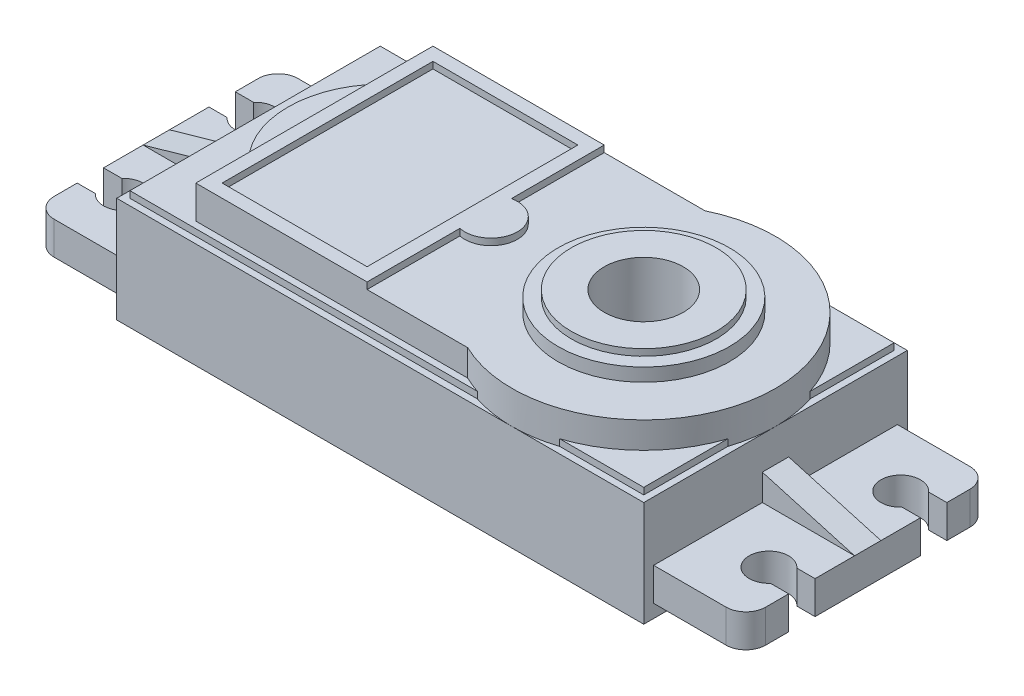
from build123d import *

# Parameters (mm, degrees)
SCHIZZO1_W                   = 40
SCHIZZO1_H                   = 20
ESTRUSIONE_ESTRUSIONE2_DEPTH = 8
TAGLIO_ESTRUSIONE4_DEPTH     = 6
ESTRUSIONE_ESTRUSIONE4_DEPTH = 2.5
SCHIZZO7_W                   = 39
SCHIZZO7_H                   = 19
ESTRUSIONE_ESTRUSIONE3_DEPTH = 0.5
SCHIZZO8_W                   = 11
SCHIZZO8_H                   = 16
ESTRUSIONE_ESTRUSIONE5_DEPTH = 0.5
SCHIZZO9_R                   = 6.5
ESTRUSIONE_ESTRUSIONE6_DEPTH = 1
SCHIZZO10_R                  = 5.5
ESTRUSIONE_ESTRUSIONE7_DEPTH = 0.5
SCHIZZO11_R                  = 3
TAGLIO_ESTRUSIONE5_DEPTH     = 26.377155081
SCHIZZO12_R                  = 1.5
ESTRUSIONE_ESTRUSIONE8_DEPTH = 2.5
TAGLIO_ESTRUSIONE6_DEPTH     = 31.020826105
SPECCHIA4_COPY_1_DEPTH       = 31.020826105
NERVATURA1_REACH             = 33.193
SCHIZZO16_WALL_W             = 71.666005732
SCHIZZO16_WALL_H             = 2


with BuildPart() as part:
    # Schizzo1 → Estrusione-Estrusione2 (new body)
    with BuildSketch(Plane(origin=(0, 0, 0), x_dir=(1, 0, 0), z_dir=(0, 1, 0))):
        Rectangle(SCHIZZO1_W, SCHIZZO1_H)
    extrude(amount=ESTRUSIONE_ESTRUSIONE2_DEPTH)

    # Schizzo2 → Taglio-Estrusione4 (cut)
    with BuildSketch(Plane(origin=(0, 0, 0), x_dir=(1, 0, 0), z_dir=(0, 1, 0))):
        Polygon((16, -8), (-16, -8), (-16, -6), (-18, -6), (-18, 6), (-16, 6), (-16, 8), (16, 8), (16, 6), (18, 6), (18, -6), (16, -6), align=None)
    extrude(amount=TAGLIO_ESTRUSIONE4_DEPTH, mode=Mode.SUBTRACT)

    # Schizzo3 → Foro per Vite M1-1 (revolve, cut)
    with BuildSketch(Plane(origin=(-17.375, 0, 7.375), x_dir=(0, 0, -1), z_dir=(1, 0, 0))):
        Polygon((0, 0), (0, 5.390559402), (0.65, 5), (0.65, 0.025), (0.675, 0), align=None)
    foro_per_vite_m1_1 = revolve(axis=Axis((-17.375, -6.35, 7.375), (0, 1, 0)), mode=Mode.SUBTRACT)

    # Specchia1: Foro per Vite M1-1 across plane
    add(foro_per_vite_m1_1.mirror(Plane(origin=(0, 0, 0), x_dir=(0, 0, 1), z_dir=(1, 0, 0))), mode=Mode.SUBTRACT)

    # Specchia2 copy 1 sketch → Specchia2 copy 1 (revolve, cut)
    with BuildSketch(Plane(origin=(17.375, 0, -7.375), x_dir=(0, 0, 1), z_dir=(-1, 0, 0))):
        Polygon((0, 0), (0, 5.390559402), (0.65, 5), (0.65, 0.025), (0.675, 0), align=None)
    revolve(axis=Axis((17.375, -6.35, -7.375), (0, 1, 0)), mode=Mode.SUBTRACT)

    # Specchia2 copy 2 sketch → Specchia2 copy 2 (revolve, cut)
    with BuildSketch(Plane(origin=(-17.375, 0, -7.375), x_dir=(0, 0, 1), z_dir=(1, 0, 0))):
        Polygon((0, 0), (0, -5.390559402), (0.65, -5), (0.65, -0.025), (0.675, 0), align=None)
    revolve(axis=Axis((-17.375, -6.35, -7.375), (0, -1, 0)), mode=Mode.SUBTRACT)

    # Taglia-Sweep3: sweep along a path in Schizzo5
    with BuildLine(Plane.XZ) as taglia_sweep3_path:
        Line((19, -9), (-19, -9))
        Line((-19, -9), (-19, 9))
        Line((-19, 9), (19, 9))
        Line((19, 9), (19, -9))
    # Schizzo4 → Taglia-Sweep3 (sweep, cut)
    with BuildSketch(Plane.XY):
        with BuildLine():
            Line((-19.25, 0), (-18.75, 0))
            ThreePointArc((-18.75, 0), (-19, 0.25), (-19.25, 0))
        make_face()
    sweep(path=taglia_sweep3_path.line, transition=Transition.RIGHT, mode=Mode.SUBTRACT)

    # Schizzo6 → Estrusione-Estrusione4 (add)
    with BuildSketch(Plane(origin=(0, 8, 0), x_dir=(1, 0, 0), z_dir=(0, 1, 0))):
        with BuildLine():
            Line((5.641101056, 9), (-15, 9))
            Line((-15, 9), (-15, 5))
            ThreePointArc((-15, 5), (-17, 0), (-15, -5))
            Line((-15, -5), (-15, -9))
            Line((-15, -9), (5.641101056, -9))
            ThreePointArc((5.641101056, -9), (20, 0), (5.641101056, 9))
        make_face()
    extrude(amount=ESTRUSIONE_ESTRUSIONE4_DEPTH)

    # Schizzo7 → Estrusione-Estrusione3 (add)
    with BuildSketch(Plane(origin=(0, 8, 0), x_dir=(1, 0, 0), z_dir=(0, 1, 0))):
        Rectangle(SCHIZZO7_W, SCHIZZO7_H)
    extrude(amount=ESTRUSIONE_ESTRUSIONE3_DEPTH)

    # Schizzo8 → Estrusione-Estrusione5 (add)
    with BuildSketch(Plane(origin=(0, 10.5, 0), x_dir=(1, 0, 0), z_dir=(0, 1, 0))):
        with BuildLine():
            Line((-15, 9), (-2, 9))
            Line((-2, 9), (-2, 1.957707578))
            ThreePointArc((-2, 1.957707578), (0.409122281, 0), (-2, -1.957707578))
            Line((-2, -1.957707578), (-2, -9))
            Line((-2, -9), (-15, -9))
            Line((-15, -9), (-15, 9))
        make_face()
        with Locations((-8.5, 0)):
            Rectangle(SCHIZZO8_W, SCHIZZO8_H, mode=Mode.SUBTRACT)
    extrude(amount=ESTRUSIONE_ESTRUSIONE5_DEPTH)

    # Schizzo9 → Estrusione-Estrusione6 (add)
    with BuildSketch(Plane(origin=(0, 10.5, 0), x_dir=(1, 0, 0), z_dir=(0, 1, 0))):
        with Locations((10, 0)):
            Circle(SCHIZZO9_R)
    extrude(amount=ESTRUSIONE_ESTRUSIONE6_DEPTH)

    # Schizzo10 → Estrusione-Estrusione7 (add)
    with BuildSketch(Plane(origin=(0, 11.5, 0), x_dir=(1, 0, 0), z_dir=(0, 1, 0))):
        with Locations((10, 0)):
            Circle(SCHIZZO10_R)
    extrude(amount=ESTRUSIONE_ESTRUSIONE7_DEPTH)

    # Schizzo11 → Taglio-Estrusione5 (cut, through all)
    with BuildSketch(Plane(origin=(0, 12, 0), x_dir=(1, 0, 0), z_dir=(0, 1, 0))):
        with Locations((10, 0)):
            Circle(SCHIZZO11_R)
    extrude(amount=-TAGLIO_ESTRUSIONE5_DEPTH, mode=Mode.SUBTRACT)

    # Schizzo12 → Estrusione-Estrusione8 (add)
    with BuildSketch(Plane(origin=(0, 1, 0), x_dir=(-1, 0, 0), z_dir=(0, -1, 0))):
        with BuildLine():
            Line((-25.5, 9.25), (-20, 9.25))
            Line((-20, 9.25), (-20, -9.25))
            Line((-20, -9.25), (-25.5, -9.25))
            ThreePointArc((-25.5, -9.25), (-26.560660172, -8.810660172), (-27, -7.75))
            Line((-27, -7.75), (-27, 7.75))
            ThreePointArc((-27, 7.75), (-26.560660172, 8.810660172), (-25.5, 9.25))
        make_face()
        with Locations((-24.5, 5)):
            Circle(SCHIZZO12_R, mode=Mode.SUBTRACT)
        with Locations((-24.5, -5)):
            Circle(SCHIZZO12_R, mode=Mode.SUBTRACT)
    estrusione_estrusione8 = extrude(amount=-ESTRUSIONE_ESTRUSIONE8_DEPTH)

    # Schizzo13 → Taglio-Estrusione6 (cut, through all)
    with BuildSketch(Plane(origin=(0, 3.5, 0), x_dir=(1, 0, 0), z_dir=(0, 1, 0))):
        with BuildLine():
            Line((25.618033989, 4), (34.322091749, 4))
            Line((34.322091749, 4), (34.322091749, 6))
            Line((34.322091749, 6), (25.618033989, 6))
            ThreePointArc((25.618033989, 6), (26, 5), (25.618033989, 4))
        make_face()
    taglio_estrusione6 = extrude(amount=-TAGLIO_ESTRUSIONE6_DEPTH, mode=Mode.SUBTRACT)

    # Specchia3: Taglio-Estrusione6 across plane
    add(taglio_estrusione6.mirror(Plane.XY), mode=Mode.SUBTRACT)

    # Specchia4: Estrusione-Estrusione8, Taglio-Estrusione6 across plane
    add(estrusione_estrusione8.mirror(Plane(origin=(0, 0, 0), x_dir=(0, 0, 1), z_dir=(1, 0, 0))))
    add(taglio_estrusione6.mirror(Plane(origin=(0, 0, 0), x_dir=(0, 0, 1), z_dir=(1, 0, 0))), mode=Mode.SUBTRACT)

    # Specchia4 copy 1 sketch → Specchia4 copy 1 (cut, through all)
    with BuildSketch(Plane(origin=(0, 3.5, 0), x_dir=(-1, 0, 0), z_dir=(0, 1, 0))):
        with BuildLine():
            Line((25.618033989, 4), (34.322091749, 4))
            Line((34.322091749, 4), (34.322091749, 6))
            Line((34.322091749, 6), (25.618033989, 6))
            ThreePointArc((25.618033989, 6), (26, 5), (25.618033989, 4))
        make_face()
    extrude(amount=-SPECCHIA4_COPY_1_DEPTH, mode=Mode.SUBTRACT)

    # Schizzo16 wall → Nervatura1 (add, up to next)
    with BuildSketch(Plane(origin=(23.5, 4.5, 0), x_dir=(-0.961523947641, 0.274721127897, 0), z_dir=(-0.274721127897, -0.961523947641, 0)), mode=Mode.PRIVATE) as nervatura1_sk1:
        Rectangle(SCHIZZO16_WALL_W, SCHIZZO16_WALL_H)
    nervatura1_tool1 = extrude(nervatura1_sk1.sketch, amount=NERVATURA1_REACH, mode=Mode.PRIVATE) - part.part
    nervatura1 = nervatura1_tool1.solids().sort_by_distance((23.5, 4.5, 0))[0]
    add(nervatura1)

    # Specchia5: Nervatura1 across plane
    add(nervatura1.mirror(Plane(origin=(0, 0, 0), x_dir=(0, 0, 1), z_dir=(1, 0, 0))))


solid = part.part
